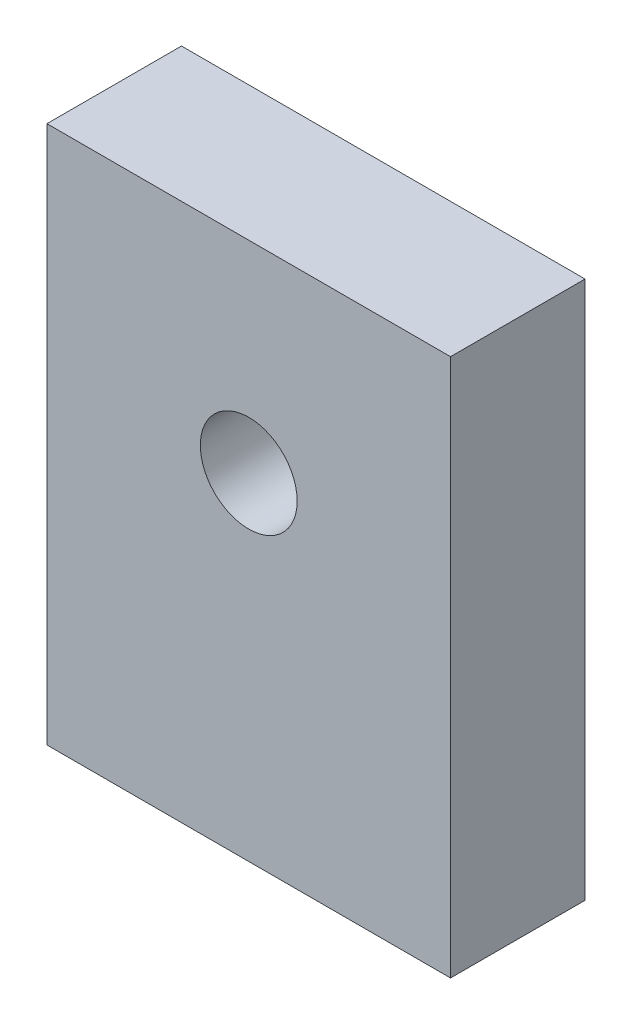
from build123d import *

# Parameters (mm, degrees)
SKETCH1_W           = 19.05
SKETCH1_H           = 25.4
SKETCH1_R           = 2.286
BOSS_EXTRUDE1_DEPTH = 6.35


with BuildPart() as part:
    # Sketch1 → Boss-Extrude1 (new body)
    with BuildSketch(Plane.XY):
        with Locations((0, 1.908882881)):
            Rectangle(SKETCH1_W, SKETCH1_H)
        with Locations((0, 5.083882881)):
            Circle(SKETCH1_R, mode=Mode.SUBTRACT)
    extrude(amount=BOSS_EXTRUDE1_DEPTH)


solid = part.part
